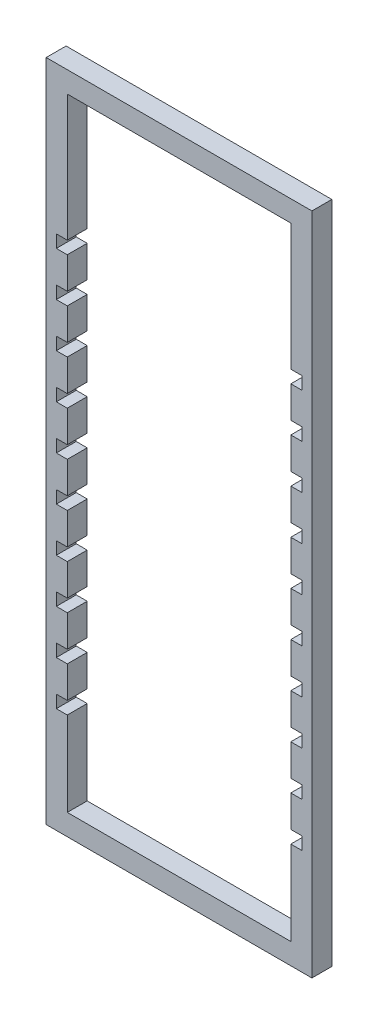
from build123d import *

# Parameters (mm, degrees)
SKETCH1_W           = 67.31
SKETCH1_H           = 187.325
BOSS_EXTRUDE1_DEPTH = 5.9944
SKETCH2_W           = 6.604
SKETCH2_H           = 3.81
CUT_EXTRUDE1_DEPTH  = 6.9944


with BuildPart() as part:
    # Sketch1 → Boss-Extrude1 (new body)
    with BuildSketch(Plane.XY):
        Polygon((0, 0), (6.35, 0), (73.66, 0), (80.01, 0), (80.01, 200.025), (73.66, 200.025), (6.35, 200.025), (0, 200.025), align=None)
        with Locations((40.005, 100.0125)):
            Rectangle(SKETCH1_W, SKETCH1_H, mode=Mode.SUBTRACT)
    extrude(amount=-BOSS_EXTRUDE1_DEPTH)

    # Sketch2 → Cut-Extrude1 (cut, through all)
    with BuildSketch(Plane.XY):
        with Locations((6.35, 33.655)):
            Rectangle(SKETCH2_W, SKETCH2_H)
        with Locations((6.35, 46.99)):
            Rectangle(SKETCH2_W, SKETCH2_H)
        with Locations((73.66, 33.655)):
            Rectangle(SKETCH2_W, SKETCH2_H)
        with Locations((73.66, 46.99)):
            Rectangle(SKETCH2_W, SKETCH2_H)
        with Locations((6.35, 60.325)):
            Rectangle(SKETCH2_W, SKETCH2_H)
        with Locations((73.66, 60.325)):
            Rectangle(SKETCH2_W, SKETCH2_H)
        with Locations((6.35, 73.66)):
            Rectangle(SKETCH2_W, SKETCH2_H)
        with Locations((73.66, 73.66)):
            Rectangle(SKETCH2_W, SKETCH2_H)
        with Locations((6.35, 86.995)):
            Rectangle(SKETCH2_W, SKETCH2_H)
        with Locations((73.66, 86.995)):
            Rectangle(SKETCH2_W, SKETCH2_H)
        with Locations((6.35, 100.33)):
            Rectangle(SKETCH2_W, SKETCH2_H)
        with Locations((73.66, 100.33)):
            Rectangle(SKETCH2_W, SKETCH2_H)
        with Locations((6.35, 113.665)):
            Rectangle(SKETCH2_W, SKETCH2_H)
        with Locations((73.66, 113.665)):
            Rectangle(SKETCH2_W, SKETCH2_H)
        with Locations((6.35, 127)):
            Rectangle(SKETCH2_W, SKETCH2_H)
        with Locations((73.66, 127)):
            Rectangle(SKETCH2_W, SKETCH2_H)
        with Locations((6.35, 140.335)):
            Rectangle(SKETCH2_W, SKETCH2_H)
        with Locations((73.66, 140.335)):
            Rectangle(SKETCH2_W, SKETCH2_H)
        with Locations((6.35, 153.67)):
            Rectangle(SKETCH2_W, SKETCH2_H)
        with Locations((73.66, 153.67)):
            Rectangle(SKETCH2_W, SKETCH2_H)
    extrude(amount=-CUT_EXTRUDE1_DEPTH, mode=Mode.SUBTRACT)


solid = part.part
